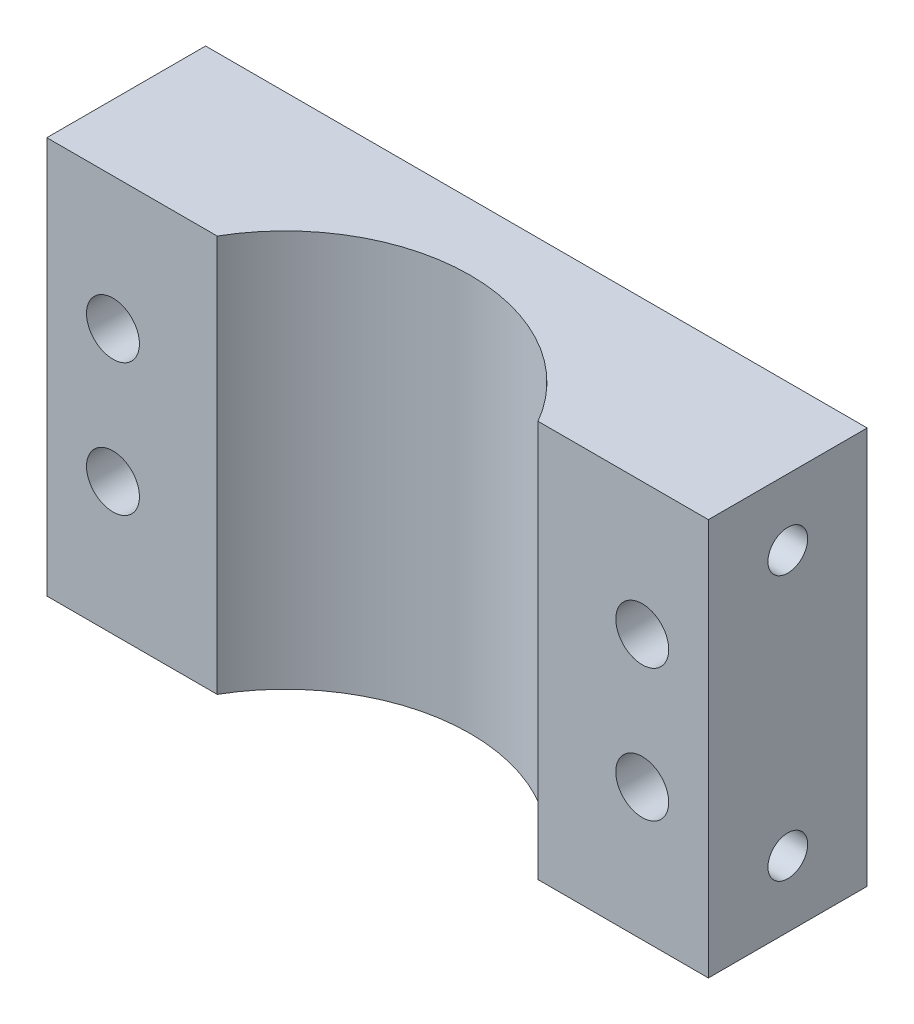
from build123d import *

# Parameters (mm, degrees)
BOSS_EXTRU_3_DEPTH      = 30
ESQUISSE1_5_W           = 12.875644347
ESQUISSE1_5_H           = 12
BOSS_EXTRU_4_DEPTH      = 30
ESQUISSE10_R            = 1.5
ENL_V_MAT_EXTRU_1_DEPTH = 3
ENL_V_START             = -3
ESQUISSE9_R             = 1.5
ENL_V_MAT_EXTRU_2_DEPTH = 3
ESQUISSE11_R            = 2
ENL_V_MAT_EXTRU_3_DEPTH = 41.853396432


with BuildPart() as part:
    # Esquisse1 → Boss.-Extru.3 (new body)
    with BuildSketch(Plane(origin=(0, 0, 0), x_dir=(1, 0, 0), z_dir=(0, 1, 0))):
        with BuildLine():
            Line((-12.124355653, 19), (-12.124355653, 7))
            ThreePointArc((-12.124355653, 7), (0, 14), (12.124355653, 7))
            Line((12.124355653, 7), (12.124355653, 19))
            Line((12.124355653, 19), (-12.124355653, 19))
        make_face()
    extrude(amount=BOSS_EXTRU_3_DEPTH)

    # Esquisse1_5 → Boss.-Extru.4 (add)
    with BuildSketch(Plane(origin=(0, 0, 0), x_dir=(1, 0, 0), z_dir=(0, 1, 0))):
        with Locations((-18.562177827, 13)):
            Rectangle(ESQUISSE1_5_W, ESQUISSE1_5_H)
        with Locations((18.562177827, 13)):
            Rectangle(ESQUISSE1_5_W, ESQUISSE1_5_H)
    extrude(amount=BOSS_EXTRU_4_DEPTH)

    # Esquisse10 → Enlèv. mat.-Extru.1 (cut)
    with BuildSketch(Plane(origin=(25, 0, 0), x_dir=(0, 0, -1), z_dir=(1, 0, 0))):
        with Locations((13, 25)):
            Circle(ESQUISSE10_R)
        with Locations((13, 5)):
            Circle(ESQUISSE10_R)
    extrude(amount=-ENL_V_MAT_EXTRU_1_DEPTH, mode=Mode.SUBTRACT)

    # Esquisse9 → Enlèv. mat.-Extru.2 (cut)
    with BuildSketch(Plane.ZY.offset(25).offset(ENL_V_START)):
        with Locations((-13, 25)):
            Circle(ESQUISSE9_R)
        with Locations((-13, 5)):
            Circle(ESQUISSE9_R)
    extrude(amount=ENL_V_MAT_EXTRU_2_DEPTH, mode=Mode.SUBTRACT)

    # Esquisse11 → Enlèv. mat.-Extru.3 (cut, through all)
    with BuildSketch(Plane(origin=(0, 0, -19), x_dir=(-1, 0, 0), z_dir=(0, 0, -1))):
        with Locations((-20, 20)):
            Circle(ESQUISSE11_R)
        with Locations((20, 20)):
            Circle(ESQUISSE11_R)
        with Locations((-20, 10)):
            Circle(ESQUISSE11_R)
        with Locations((20, 10)):
            Circle(ESQUISSE11_R)
    extrude(amount=-ENL_V_MAT_EXTRU_3_DEPTH, mode=Mode.SUBTRACT)


solid = part.part
